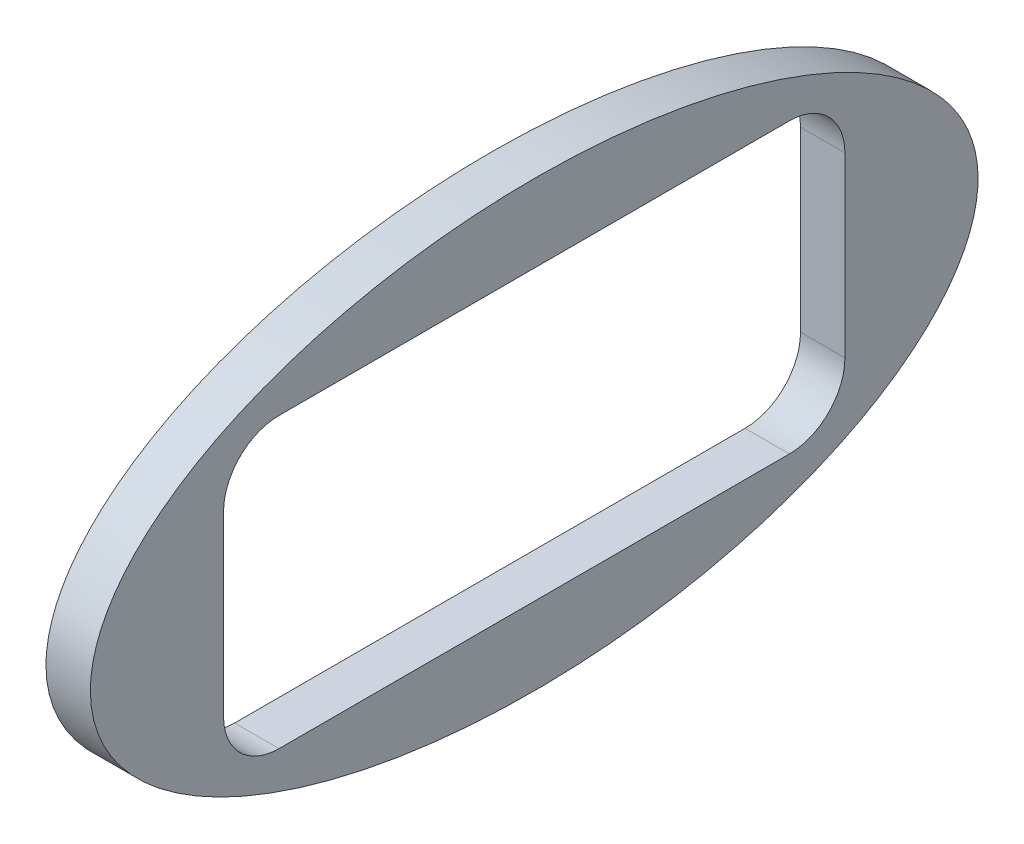
from build123d import *

# Parameters (mm, degrees)
OUTER_SKETCH_RX   = 10
OUTER_SKETCH_RY   = 5
LED_BODY_DEPTH    = 1
LED_SURFACE_DEPTH = 2


with BuildPart() as part:
    # Outer_sketch → LED_body (new body)
    with BuildSketch(Plane(origin=(0, 0, 0), x_dir=(0, 0, -1), z_dir=(1, 0, 0))):
        with Locations(Location((0, 0), (0, 0, 180))):
            Ellipse(OUTER_SKETCH_RX, OUTER_SKETCH_RY)
    extrude(amount=LED_BODY_DEPTH)

    # Hole_sketch → LED_surface (cut, through all)
    with BuildSketch(Plane(origin=(0, 0, 0), x_dir=(0, 0, -1), z_dir=(1, 0, 0))):
        with BuildLine():
            Line((-7, -2), (-7, 2))
            ThreePointArc((-7, 2), (-6.633883476, 2.883883476), (-5.75, 3.25))
            Line((-5.75, 3.25), (5.75, 3.25))
            ThreePointArc((5.75, 3.25), (6.633883476, 2.883883476), (7, 2))
            Line((7, 2), (7, -2))
            ThreePointArc((7, -2), (6.633883476, -2.883883476), (5.75, -3.25))
            Line((5.75, -3.25), (-5.75, -3.25))
            ThreePointArc((-5.75, -3.25), (-6.633883476, -2.883883476), (-7, -2))
        make_face()
    extrude(amount=LED_SURFACE_DEPTH, mode=Mode.SUBTRACT)


solid = part.part
